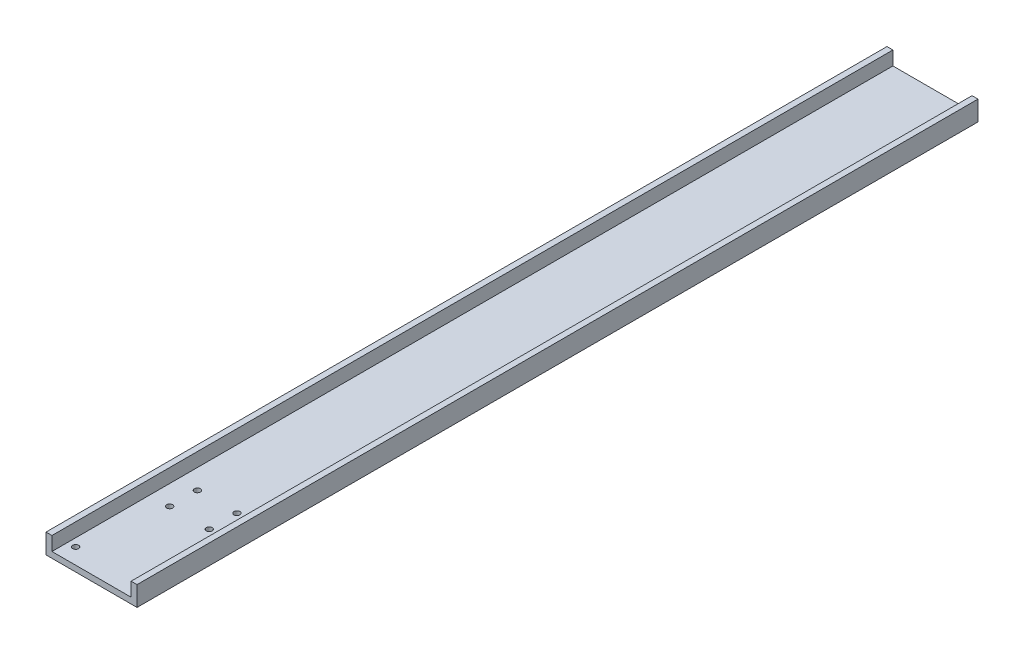
from build123d import *

# Parameters (mm, degrees)
BOSS_EXTRUDE1_DEPTH       = 425
F_3_0MM_DOWEL_HOLE1_D     = 3
F_3_0MM_DOWEL_HOLE1_DEPTH = 15
F_3_0MM_DOWEL_HOLE1_TIP   = 0.901290929
F_3_0MM_DOWEL_HOLE2_D     = 3
F_3_0MM_DOWEL_HOLE2_DEPTH = 15
F_3_0MM_DOWEL_HOLE2_TIP   = 0.901290929


with BuildPart() as part:
    # Sketch1 → Boss-Extrude1 (new body)
    with BuildSketch(Plane.XY):
        Polygon((0, 0), (0, 7), (-3, 7), (-3, -3), (43, -3), (43, 7), (40, 7), (40, 0), align=None)
    extrude(amount=BOSS_EXTRUDE1_DEPTH)

    # Ø3.0mm Dowel Hole1
    with Locations(Plane(origin=(0, 0, 0), x_dir=(1, 0, 0), z_dir=(0, 1, 0))):
        with Locations((10, -375.5), (30, -375.5), (30, -361.5), (10, -361.5)):
            Hole(F_3_0MM_DOWEL_HOLE1_D / 2, depth=F_3_0MM_DOWEL_HOLE1_DEPTH)
            with Locations((0, 0, -(F_3_0MM_DOWEL_HOLE1_DEPTH + F_3_0MM_DOWEL_HOLE1_TIP / 2))):  # 118° drill point
                Cone(0, F_3_0MM_DOWEL_HOLE1_D / 2, F_3_0MM_DOWEL_HOLE1_TIP, mode=Mode.SUBTRACT)

    # Ø3.0mm Dowel Hole2
    with Locations(Plane(origin=(0, -3, 0), x_dir=(-1, 0, 0), z_dir=(0, -1, 0))):
        with Locations((-36, -417), (-4, -417)):
            Hole(F_3_0MM_DOWEL_HOLE2_D / 2, depth=F_3_0MM_DOWEL_HOLE2_DEPTH)
            with Locations((0, 0, -(F_3_0MM_DOWEL_HOLE2_DEPTH + F_3_0MM_DOWEL_HOLE2_TIP / 2))):  # 118° drill point
                Cone(0, F_3_0MM_DOWEL_HOLE2_D / 2, F_3_0MM_DOWEL_HOLE2_TIP, mode=Mode.SUBTRACT)


solid = part.part
